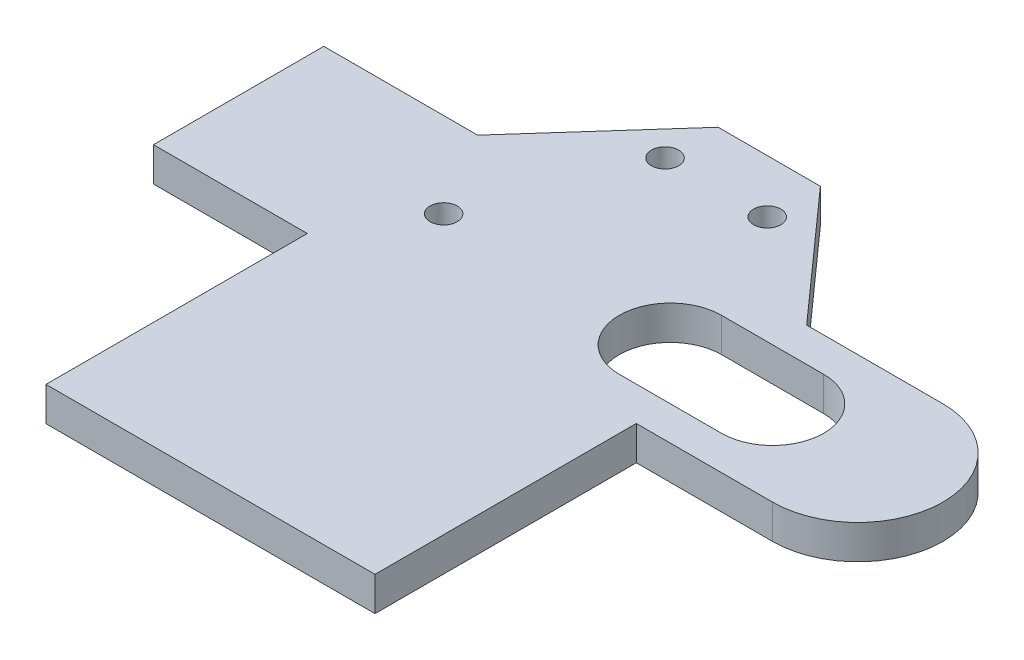
from build123d import *

# Parameters (mm, degrees)
SKETCH1_R           = 4
BOSS_EXTRUDE1_DEPTH = 10
SCALE1_SCALE        = 0.5


with BuildPart() as part:
    # Sketch1 → Boss-Extrude1 (new body)
    with BuildSketch(Plane(origin=(0, 0, 0), x_dir=(1, 0, 0), z_dir=(0, 1, 0))):
        with BuildLine():
            Line((-28.284271247, 28.284271247), (-28.284271247, -48.415659381))
            Line((-28.284271247, -48.415659381), (63.338627893, -48.415659381))
            Line((63.338627893, -48.415659381), (68.284271247, -48.415659381))
            Line((68.284271247, -48.415659381), (68.284271247, 28.284271247))
            Line((68.284271247, 28.284271247), (108.284271247, 28.284271247))
            ThreePointArc((108.284271247, 28.284271247), (133.284271247, 53.284271247), (108.284271247, 78.284271247))
            Line((108.284271247, 78.284271247), (68.284271247, 78.284271247))
            Line((68.284271247, 78.284271247), (35, 115.595895274))
            Line((35, 115.595895274), (5, 115.595895274))
            Line((5, 115.595895274), (-28.284271247, 78.284271247))
            Line((-28.284271247, 78.284271247), (-73.439346791, 78.284271247))
            Line((-73.439346791, 78.284271247), (-73.439346791, 28.284271247))
            Line((-73.439346791, 28.284271247), (-28.284271247, 28.284271247))
        make_face()
        with Locations((5, 100)):
            Circle(SKETCH1_R, mode=Mode.SUBTRACT)
        with Locations((35, 100)):
            Circle(SKETCH1_R, mode=Mode.SUBTRACT)
        with Locations((-13.284271247, 53.284271247)):
            Circle(SKETCH1_R, mode=Mode.SUBTRACT)
        with BuildLine():
            Line((53.284271247, 68.284271247), (83.284271247, 68.284271247))
            ThreePointArc((83.284271247, 68.284271247), (98.284271247, 53.284271247), (83.284271247, 38.284271247))
            Line((83.284271247, 38.284271247), (53.284271247, 38.284271247))
            ThreePointArc((53.284271247, 38.284271247), (38.284271247, 53.284271247), (53.284271247, 68.284271247))
        make_face(mode=Mode.SUBTRACT)
    extrude(amount=BOSS_EXTRUDE1_DEPTH)


with BuildPart() as part_1:
    # Scale1: scaled about (19.875908693, 5, -32.344377814)
    add(part.part.scale(SCALE1_SCALE).moved(Location((9.937954346, 2.5, -16.172188907))))


solid = part_1.part
